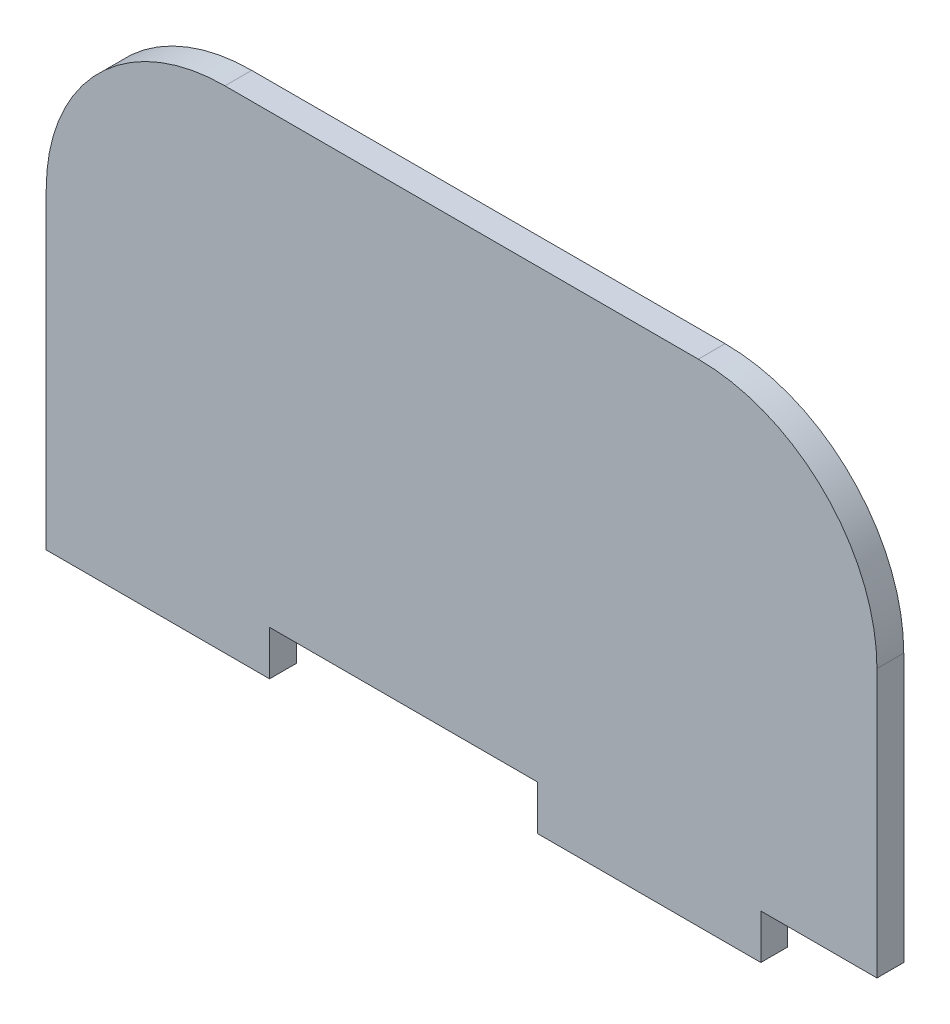
from build123d import *

# Parameters (mm, degrees)
RESSALTO_EXTRUS_O1_DEPTH = 3


with BuildPart() as part:
    # Esboço1 → Ressalto-extrusão1 (new body)
    with BuildSketch(Plane.XY):
        with BuildLine():
            Line((43.040081042, -1.381695114), (56.040081042, -1.381695114))
            Line((56.040081042, -1.381695114), (56.040081042, 28.618304886))
            ThreePointArc((56.040081042, 28.618304886), (50.182216666, 42.76044051), (36.040081042, 48.618304886))
            Line((36.040081042, 48.618304886), (-16.959918958, 48.618304886))
            ThreePointArc((-16.959918958, 48.618304886), (-31.102054581, 42.76044051), (-36.959918958, 28.618304886))
            Line((-36.959918958, 28.618304886), (-36.959918958, -1.381695114))
            Line((-36.959918958, -1.381695114), (-36.959918958, -6.381695114))
            Line((-36.959918958, -6.381695114), (-11.959918958, -6.381695114))
            Line((-11.959918958, -6.381695114), (-11.959918958, -1.381695114))
            Line((-11.959918958, -1.381695114), (18.040081042, -1.381695114))
            Line((18.040081042, -1.381695114), (18.040081042, -6.381695114))
            Line((18.040081042, -6.381695114), (43.040081042, -6.381695114))
            Line((43.040081042, -6.381695114), (43.040081042, -1.381695114))
        make_face()
    extrude(amount=RESSALTO_EXTRUS_O1_DEPTH)


solid = part.part
